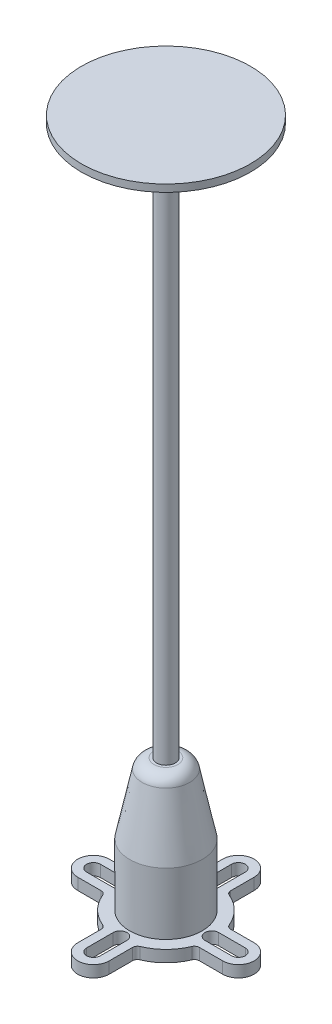
from build123d import *

# Parameters (mm, degrees)
BOSS_EXTRUDE1_DEPTH   = 2.4
FILLET1_R             = 1
SKETCH3_R             = 1.9225
BOSS_EXTRUDE2_DEPTH   = 141
KES_EKSTR_ZYON1_DEPTH = 0.06


with BuildPart() as part:
    # Sketch1 → Boss-Extrude1 (new body)
    with BuildSketch(Plane(origin=(0, 0, 0), x_dir=(1, 0, 0), z_dir=(0, 1, 0))):
        with BuildLine():
            Line((-15, 3.25), (-9.45714016, 3.25))
            ThreePointArc((-9.45714016, 3.25), (-7.071067812, 7.071067812), (-3.25, 9.45714016))
            Line((-3.25, 9.45714016), (-3.25, 15))
            ThreePointArc((-3.25, 15), (0, 18.25), (3.25, 15))
            Line((3.25, 15), (3.25, 9.45714016))
            ThreePointArc((3.25, 9.45714016), (7.071067812, 7.071067812), (9.45714016, 3.25))
            Line((9.45714016, 3.25), (15, 3.25))
            ThreePointArc((15, 3.25), (18.25, 0), (15, -3.25))
            Line((15, -3.25), (9.45714016, -3.25))
            ThreePointArc((9.45714016, -3.25), (7.071067812, -7.071067812), (3.25, -9.45714016))
            Line((3.25, -9.45714016), (3.25, -15))
            ThreePointArc((3.25, -15), (0, -18.25), (-3.25, -15))
            Line((-3.25, -15), (-3.25, -9.45714016))
            ThreePointArc((-3.25, -9.45714016), (-7.071067812, -7.071067812), (-9.45714016, -3.25))
            Line((-9.45714016, -3.25), (-15, -3.25))
            ThreePointArc((-15, -3.25), (-18.25, 0), (-15, 3.25))
        make_face()
        with BuildLine():
            Line((-15, 1.42), (-9.5, 1.42))
            ThreePointArc((-9.5, 1.42), (-8.08, 0), (-9.5, -1.42))
            Line((-9.5, -1.42), (-15, -1.42))
            ThreePointArc((-15, -1.42), (-16.42, 0), (-15, 1.42))
        make_face(mode=Mode.SUBTRACT)
        with BuildLine():
            Line((1.42, 15), (1.42, 9.5))
            ThreePointArc((1.42, 9.5), (0, 8.08), (-1.42, 9.5))
            Line((-1.42, 9.5), (-1.42, 15))
            ThreePointArc((-1.42, 15), (0, 16.42), (1.42, 15))
        make_face(mode=Mode.SUBTRACT)
        with BuildLine():
            Line((15, -1.42), (9.5, -1.42))
            ThreePointArc((9.5, -1.42), (8.08, 0), (9.5, 1.42))
            Line((9.5, 1.42), (15, 1.42))
            ThreePointArc((15, 1.42), (16.42, 0), (15, -1.42))
        make_face(mode=Mode.SUBTRACT)
        with BuildLine():
            Line((-1.42, -15), (-1.42, -9.5))
            ThreePointArc((-1.42, -9.5), (0, -8.08), (1.42, -9.5))
            Line((1.42, -9.5), (1.42, -15))
            ThreePointArc((1.42, -15), (0, -16.42), (-1.42, -15))
        make_face(mode=Mode.SUBTRACT)
    extrude(amount=BOSS_EXTRUDE1_DEPTH)

    # Fillet1
    fillet1_edges = [part.edges().sort_by_distance(p)[0] for p in [
        (-9.45714016, 1.2, -3.25),
        (-3.25, 1.2, -9.45714016),
        (3.25, 1.2, -9.45714016),
        (9.45714016, 1.2, -3.25),
        (9.45714016, 1.2, 3.25),
        (3.25, 1.2, 9.45714016),
        (-3.25, 1.2, 9.45714016),
        (-9.45714016, 1.2, 3.25),
    ]]
    fillet(fillet1_edges, radius=FILLET1_R)

    # Sketch2 → Revolve1 (revolve)
    with BuildSketch(Plane.XY):
        with BuildLine():
            Line((1.925, 29.7), (2.464294328, 29.7))
            ThreePointArc((2.464294328, 29.7), (4.04285617, 29.138592921), (4.912445377, 27.70651401))
            Line((4.912445377, 27.70651401), (7.5, 15.2))
            Line((7.5, 15.2), (7.5, 2.4))
            Line((7.5, 2.4), (5.625, 2.4))
            Line((5.625, 2.4), (5.625, 15.2))
            Line((5.625, 15.2), (3.404891948, 26.194820827))
            ThreePointArc((3.404891948, 26.194820827), (2.889371485, 27.2829386), (1.925, 28.003874988))
            Line((1.925, 28.003874988), (1.925, 29.7))
        make_face()
    revolve(axis=Axis((0, 2.4, 0), (0, 1, 0)))

    # Sketch3 → Boss-Extrude2 (add)
    with BuildSketch(Plane(origin=(0, 2.4, 0), x_dir=(1, 0, 0), z_dir=(0, 1, 0))):
        Circle(SKETCH3_R)
    extrude(amount=BOSS_EXTRUDE2_DEPTH)

    # Sketch4 → Revolve2 (revolve)
    with BuildSketch(Plane(origin=(0, 0, 0), x_dir=(0, 0, -1), z_dir=(1, 0, 0))):
        with BuildLine():
            Line((6.922649731, 142.4), (3.230934575, 136.005761782))
            ThreePointArc((3.230934575, 136.005761782), (2.938114252, 135.712941459), (2.538114252, 135.605761782))
            Line((2.538114252, 135.605761782), (1.9225, 135.605761782))
            Line((1.9225, 135.605761782), (1.9225, 143.4))
            Line((1.9225, 143.4), (0, 143.4))
            Line((0, 143.4), (0, 144.9))
            Line((0, 144.9), (17.5, 144.9))
            Line((17.5, 144.9), (17.5, 143.4))
            Line((17.5, 143.4), (8.654700538, 143.4))
            ThreePointArc((8.654700538, 143.4), (7.654700538, 143.132050808), (6.922649731, 142.4))
        make_face()
    revolve(axis=Axis((0, 143.4, 0), (0, -1, 0)))

    # Çizim1 → Kes-Ekstrüzyon1 (cut)
    with BuildSketch(Plane.XZ.offset(-143.4)):
        Polygon((2.473531895, 11.056579199), (2.409957676, 10.172692481), (0.082320957, 10.339489356), (0.334567051, 13.859997168), (2.66220377, 13.693200293), (2.599313145, 12.809997168), (1.511715488, 12.887926856), (1.480270176, 12.451794043), (2.237008457, 12.397790137), (2.173434238, 11.513903418), (1.416695957, 11.567907324), (1.385934238, 11.134508887), align=None)
        Polygon((3.792276096, 9.57689352), (2.680752659, 10.121717739), (5.101358127, 12.856776332), (6.685244846, 12.080213832), (6.008487034, 8.490663051), (4.89764719, 9.034803676), (5.015225315, 9.640467739), (4.199014377, 10.040370082), align=None)
        Polygon((4.76639719, 10.68704977), (5.177920627, 10.485389614), (5.35702219, 11.371327114), align=None, mode=Mode.SUBTRACT)
        with BuildLine():
            Line((10.49023887, 8.045909213), (9.301469339, 7.814170932))
            add(Edge.make_bspline(
                [(9.301469339, 7.814170932), (9.295162601, 7.849093276), (9.282863589, 7.91719668), (9.259765757, 8.016165899), (9.231766875, 8.109044475), (9.199649304, 8.196046435), (9.163730366, 8.277260103), (9.122086055, 8.351638268), (9.078384744, 8.421598141), (9.044202502, 8.463454613), (9.027348245, 8.484092807)],
                knots=[0, 0, 0, 0, 0.000106452, 0.000207596, 0.000304698, 0.000397269, 0.000485696, 0.00057075, 0.000652855, 0.000732716, 0.000732716, 0.000732716, 0.000732716], degree=3))
            add(Edge.make_bspline(
                [(9.027348245, 8.484092807), (9.01594409, 8.496831925), (8.993668142, 8.52171548), (8.957180327, 8.554902215), (8.918891069, 8.58263641), (8.879448715, 8.606805989), (8.837738681, 8.624547904), (8.795060394, 8.639748228), (8.750352942, 8.648261409), (8.689312805, 8.653650441), (8.61134576, 8.649600922), (8.51970475, 8.622824869), (8.429383641, 8.578500593), (8.375376925, 8.535791651), (8.347172464, 8.513487338)],
                knots=[0, 0, 0, 0, 5.1274e-05, 0.000100155, 0.000147599, 0.000192969, 0.000238571, 0.000283319, 0.000328632, 0.000374616, 0.000467063, 0.000560776, 0.000659216, 0.00076682, 0.00076682, 0.00076682, 0.00076682], degree=3))
            add(Edge.make_bspline(
                [(8.347172464, 8.513487338), (8.32238698, 8.49082732), (8.275523945, 8.447982998), (8.221828166, 8.374475546), (8.186518469, 8.299074978), (8.171541706, 8.220584969), (8.176882746, 8.140146557), (8.201970979, 8.058369087), (8.24745169, 7.976028431), (8.288027536, 7.924336237), (8.309574808, 7.896885776)],
                knots=[0, 0, 0, 0, 0.000100546, 0.000190108, 0.000271179, 0.000348404, 0.000427163, 0.000510645, 0.000603011, 0.000707603, 0.000707603, 0.000707603, 0.000707603], degree=3))
            Line((8.309574808, 7.896885776), (8.728617776, 8.253038119))
            Line((8.728617776, 8.253038119), (9.527055276, 7.314463901))
            Line((9.527055276, 7.314463901), (8.085356058, 6.088096713))
            add(Edge.make_bspline(
                [(8.085356058, 6.088096713), (8.043412666, 6.130918963), (7.963019255, 6.212996893), (7.848036495, 6.330909372), (7.745125301, 6.439426088), (7.651824198, 6.535975119), (7.570495488, 6.623033205), (7.499975002, 6.699500807), (7.440576701, 6.765659164), (7.404913451, 6.806519435), (7.388774026, 6.825010776)],
                knots=[0, 0, 0, 0, 0.000179825, 0.000344674, 0.000494074, 0.000628484, 0.000747456, 0.000851473, 0.000940545, 0.001014176, 0.001014176, 0.001014176, 0.001014176], degree=3))
            add(Edge.make_bspline(
                [(7.388774026, 6.825010776), (7.362058603, 6.85691328), (7.309444418, 6.919743064), (7.236989178, 7.015916122), (7.169853497, 7.110629262), (7.110069184, 7.204873936), (7.055748887, 7.297651818), (7.008392801, 7.389665379), (6.967289467, 7.480685486), (6.932054654, 7.570889978), (6.904285219, 7.660554079), (6.881879716, 7.748984602), (6.867047818, 7.836567991), (6.8580281, 7.923104859), (6.855033423, 8.008796842), (6.859351934, 8.093567562), (6.869528685, 8.177437845), (6.89179563, 8.287308778), (6.930587621, 8.421570582), (6.989518301, 8.577515834), (7.059974362, 8.728287923), (7.144056677, 8.87248116), (7.238974286, 9.012055008), (7.347673596, 9.144627972), (7.468154157, 9.271895089), (7.556552427, 9.35016865), (7.601371683, 9.389854526)],
                knots=[0, 0, 0, 0, 0.000124813, 0.000245811, 0.00036112, 0.000473004, 0.00058052, 0.000683552, 0.000783294, 0.000880029, 0.000973863, 0.001064719, 0.001153502, 0.001240092, 0.001325585, 0.00141045, 0.001494477, 0.001578803, 0.001746506, 0.001913085, 0.002078523, 0.002245136, 0.00241332, 0.002584355, 0.002758907, 0.002938427, 0.002938427, 0.002938427, 0.002938427], degree=3))
            add(Edge.make_bspline(
                [(7.601371683, 9.389854526), (7.633267182, 9.416124727), (7.696616127, 9.468301038), (7.794804449, 9.540632275), (7.89522225, 9.606383047), (7.996644151, 9.666761034), (8.100532816, 9.720065252), (8.205586837, 9.768027651), (8.312583613, 9.809888085), (8.420955565, 9.84541849), (8.529824651, 9.873991879), (8.63797322, 9.895680951), (8.744963509, 9.908130177), (8.850675885, 9.915266481), (8.955311133, 9.911662891), (9.058901226, 9.902751782), (9.161192476, 9.884483788), (9.262208706, 9.859340021), (9.361575353, 9.826665303), (9.457961526, 9.785512166), (9.551318063, 9.73663609), (9.641991537, 9.680468107), (9.72947251, 9.615894492), (9.814300197, 9.543841789), (9.89671096, 9.464752006), (9.947642677, 9.406869871), (9.973441995, 9.377549838)],
                knots=[0, 0, 0, 0, 0.000123949, 0.000246181, 0.000365628, 0.000483921, 0.000600102, 0.000715741, 0.000830244, 0.0009446, 0.001057681, 0.001167748, 0.001275177, 0.00138063, 0.001485255, 0.001588921, 0.001692315, 0.001796601, 0.001901012, 0.002005762, 0.002110638, 0.002216866, 0.002325426, 0.002436499, 0.002550592, 0.002667712, 0.002667712, 0.002667712, 0.002667712], degree=3))
            add(Edge.make_bspline(
                [(9.973441995, 9.377549838), (10.008964061, 9.333535211), (10.080876677, 9.244429836), (10.173686342, 9.096785456), (10.258402353, 8.938194374), (10.331918381, 8.768701017), (10.393760496, 8.59235643), (10.441989787, 8.412398366), (10.475629511, 8.230183983), (10.485369339, 8.107330913), (10.49023887, 8.045909213)],
                knots=[0, 0, 0, 0, 0.000169553, 0.000343252, 0.000522153, 0.000708588, 0.000896894, 0.001082278, 0.001267051, 0.001451795, 0.001451795, 0.001451795, 0.001451795], degree=3))
        make_face()
    extrude(amount=-KES_EKSTR_ZYON1_DEPTH, mode=Mode.SUBTRACT)


solid = part.part
